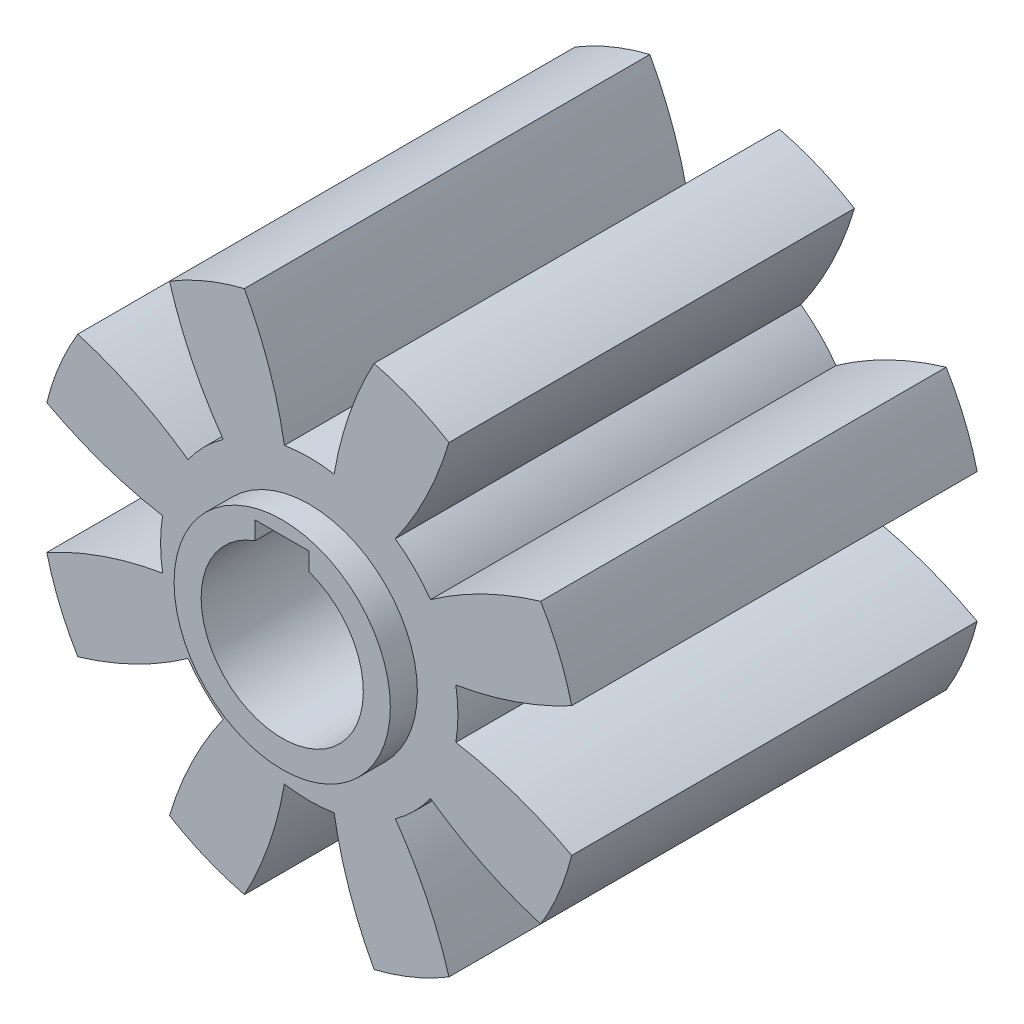
from build123d import *

# Parameters (mm, degrees)
SKETCH1_R               = 10
BOSS_EXTRUDE1_DEPTH     = 7.5
CUT_EXTRUDE1_DEPTH      = 17.007810594
SKETCH3_R               = 4
BOSS_EXTRUDE2_DEPTH     = 1
CUT_EXTRUDE2_DEPTH      = 22.354156504
CUT_EXTRUDE2_DEPTH_BACK = 22.354156504
CIRPATTERN2_COUNT       = 8


with BuildPart() as part:
    # Sketch1 → Boss-Extrude1 (new, symmetric)
    with BuildSketch(Plane.XY):
        Circle(SKETCH1_R)
    extrude(amount=BOSS_EXTRUDE1_DEPTH, both=True)

    # Sketch2 → Cut-Extrude1 (cut, symmetric)
    with BuildSketch(Plane.XY):
        with BuildLine():
            ThreePointArc((0.919743931, 5.422552084), (0, 5.5), (-0.919743931, 5.422552084))
            ThreePointArc((-0.919743931, 5.422552084), (-1.482705591, 7.626183267), (-2.398327114, 9.708142307))
            ThreePointArc((-2.398327114, 9.708142307), (0, 10), (2.398327114, 9.708142307))
            ThreePointArc((2.398327114, 9.708142307), (1.482705591, 7.626183267), (0.919743931, 5.422552084))
        make_face()
    cut_extrude1 = extrude(amount=CUT_EXTRUDE1_DEPTH, both=True, mode=Mode.SUBTRACT)

    # Sketch3 → Boss-Extrude2 (add, symmetric)
    with BuildSketch(Plane.XY.offset(7.5)):
        Circle(SKETCH3_R)
        with BuildLine():
            Line((-1, 2.828427125), (-1, 3.495093791))
            Line((-1, 3.495093791), (1, 3.495093791))
            Line((1, 3.495093791), (1, 2.828427125))
            ThreePointArc((1, 2.828427125), (0, -3), (-1, 2.828427125))
        make_face(mode=Mode.SUBTRACT)
    boss_extrude2 = extrude(amount=BOSS_EXTRUDE2_DEPTH, both=True)

    # Mirror1: Boss-Extrude2 across plane
    add(boss_extrude2.mirror(Plane.XY))

    # Sketch3_3 → Cut-Extrude2 (cut, two sides: drawn at the far end of the back side and taken through both)
    with BuildSketch(Plane.XY.offset(7.5).offset(-CUT_EXTRUDE2_DEPTH_BACK)):
        with BuildLine():
            Line((1, 3.495093791), (-1, 3.495093791))
            Line((-1, 3.495093791), (-1, 2.828427125))
            ThreePointArc((-1, 2.828427125), (0, -3), (1, 2.828427125))
            Line((1, 2.828427125), (1, 3.495093791))
        make_face()
    extrude(amount=CUT_EXTRUDE2_DEPTH + CUT_EXTRUDE2_DEPTH_BACK, mode=Mode.SUBTRACT)

    # CirPattern2: Cut-Extrude1 ×8 about axis
    cirpattern2_axis = Axis((0, 0, 7.5), (0, 0, 1))
    for i in range(1, CIRPATTERN2_COUNT):
        add(cut_extrude1.rotate(cirpattern2_axis, i * 360 / CIRPATTERN2_COUNT), mode=Mode.SUBTRACT)


solid = part.part
